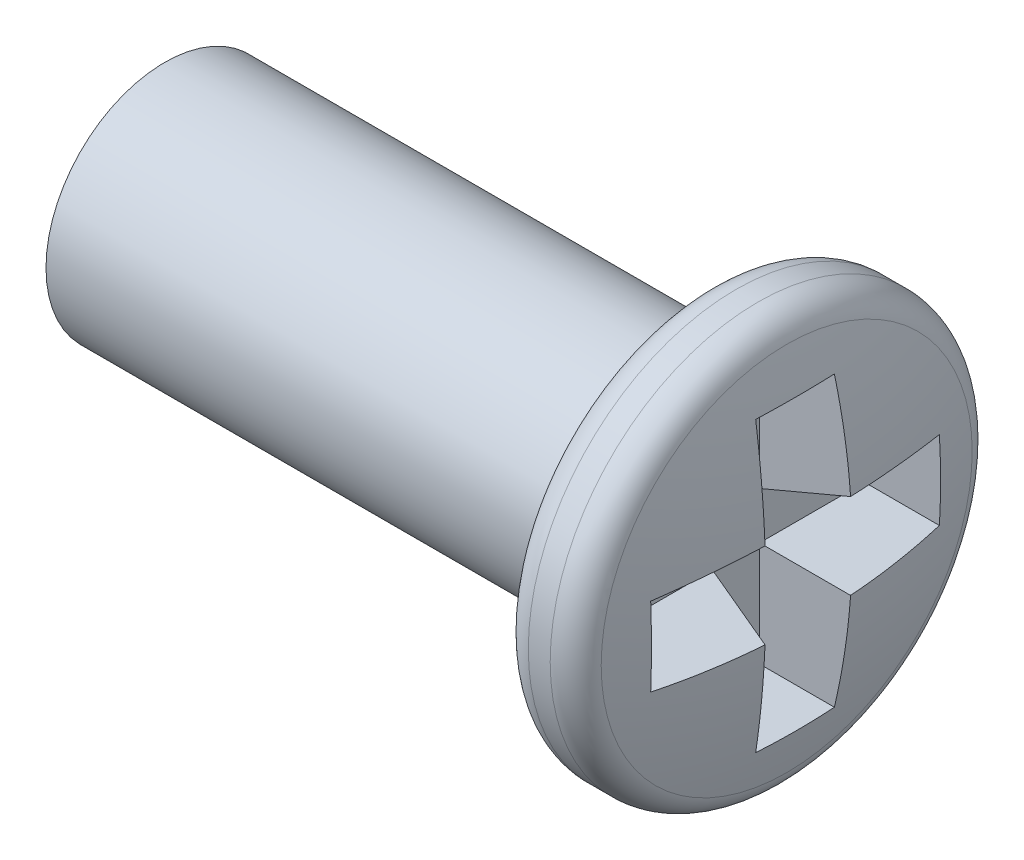
from build123d import *

# Parameters (mm, degrees)
FILLET1_R          = 0.2
CUT_EXTRUDE1_DEPTH = 0.5
CUT_EXTRUDE1_TAPER = 15


with BuildPart() as part:
    # Sketch1 → Revolve1 (revolve)
    with BuildSketch(Plane.XY):
        with BuildLine():
            Line((0, 0), (4.35, 0))
            ThreePointArc((4.35, 0), (4.299747468, 0.707106781), (4.15, 1.4))
            Line((4.15, 1.4), (3.65, 1.4))
            Line((3.65, 1.4), (3.65, 0.8))
            Line((3.65, 0.8), (0, 0.8))
            Line((0, 0.8), (0, 0))
        make_face()
    revolve(axis=Axis((-102.03816923, 0, 0), (1, 0, 0)))

    # Fillet1
    fillet1_edges = [part.edges().sort_by_distance(p)[0] for p in [
        (3.65, -1.4, 0),
        (4.15, -1.4, 0),
    ]]
    fillet(fillet1_edges, radius=FILLET1_R)

    # Sketch2 → Cut-Extrude1 (cut)
    with BuildSketch(Plane(origin=(4.35, 0, 0), x_dir=(0, 0, -1), z_dir=(1, 0, 0))):
        Polygon((0.29273093, 1), (-0.29273093, 1), (-0.29273093, 0.29273093), (-1, 0.29273093), (-1, -0.29273093), (-0.29273093, -0.29273093), (-0.29273093, -1), (0.29273093, -1), (0.29273093, -0.29273093), (1, -0.29273093), (1, 0.29273093), (0.29273093, 0.29273093), align=None)
    extrude(amount=-CUT_EXTRUDE1_DEPTH, taper=CUT_EXTRUDE1_TAPER, mode=Mode.SUBTRACT)


solid = part.part
